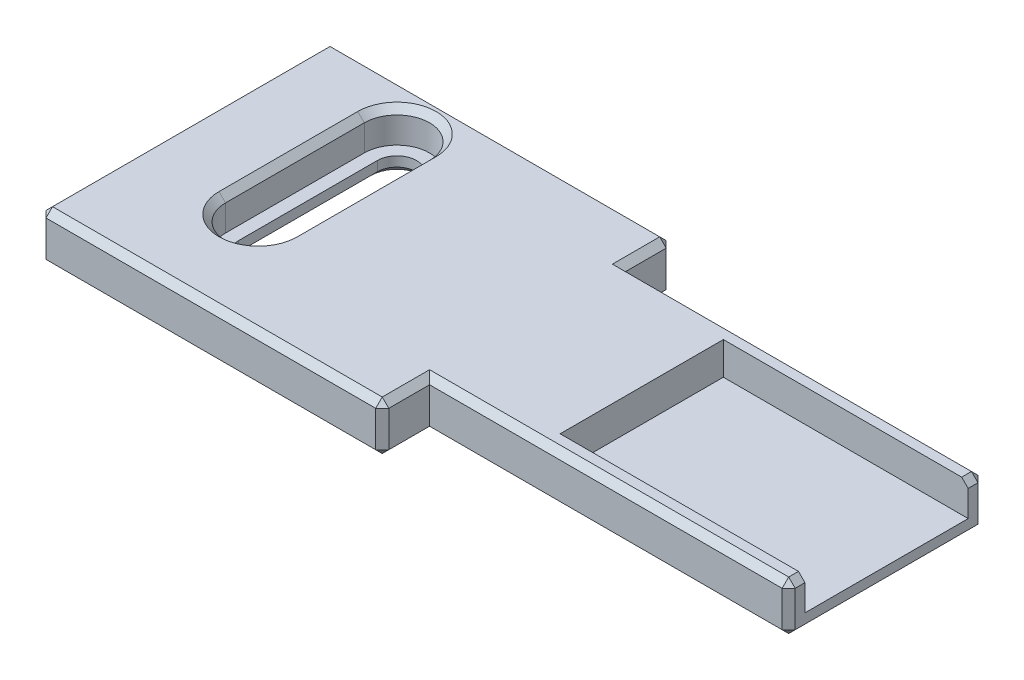
from build123d import *

# Parameters (mm, degrees)
SKETCH1_W           = 43
SKETCH1_H           = 17.8
BOSS_EXTRUDE1_DEPTH = 3
SKETCH2_W           = 22
SKETCH2_H           = 2.9
CUT_EXTRUDE1_DEPTH  = 4
SKETCH3_W           = 22
SKETCH3_H           = 2.9
CUT_EXTRUDE2_DEPTH  = 4
CUT_EXTRUDE3_DEPTH  = 2
CUT_EXTRUDE4_DEPTH  = 4
SKETCH6_W           = 10
SKETCH6_H           = 2
CUT_EXTRUDE5_DEPTH  = 15
CHAMFER1_SIZE       = 0.4


with BuildPart() as part:
    # Sketch1 → Boss-Extrude1 (new body)
    with BuildSketch(Plane(origin=(0, 38, 0), x_dir=(1, 0, 0), z_dir=(0, 1, 0))):
        with Locations((-6.5, 6)):
            Rectangle(SKETCH1_W, SKETCH1_H)
    extrude(amount=-BOSS_EXTRUDE1_DEPTH)

    # Sketch2 → Cut-Extrude1 (cut, through all)
    with BuildSketch(Plane.XZ.offset(-35)):
        with Locations((4, 1.45)):
            Rectangle(SKETCH2_W, SKETCH2_H)
    extrude(amount=-CUT_EXTRUDE1_DEPTH, mode=Mode.SUBTRACT)

    # Sketch3 → Cut-Extrude2 (cut, through all)
    with BuildSketch(Plane.XZ.offset(-35)):
        with Locations((4, -13.45)):
            Rectangle(SKETCH3_W, SKETCH3_H)
    extrude(amount=-CUT_EXTRUDE2_DEPTH, mode=Mode.SUBTRACT)

    # Sketch4 → Cut-Extrude3 (cut)
    with BuildSketch(Plane(origin=(0, 38, 0), x_dir=(-1, 0, 0), z_dir=(0, 1, 0))):
        with BuildLine():
            Line((22.9, -11.9), (22.9, -3.4))
            ThreePointArc((22.9, -3.4), (20.9, -1.4), (18.9, -3.4))
            Line((18.9, -3.4), (18.9, -11.9))
            ThreePointArc((18.9, -11.9), (20.9, -13.9), (22.9, -11.9))
        make_face()
    extrude(amount=-CUT_EXTRUDE3_DEPTH, mode=Mode.SUBTRACT)

    # Sketch5 → Cut-Extrude4 (cut, through all)
    with BuildSketch(Plane.XZ.offset(-35)):
        with BuildLine():
            Line((-22.1, -3.4), (-22.1, -11.9))
            ThreePointArc((-22.1, -11.9), (-20.9, -13.1), (-19.7, -11.9))
            Line((-19.7, -11.9), (-19.7, -3.4))
            ThreePointArc((-19.7, -3.4), (-20.9, -2.2), (-22.1, -3.4))
        make_face()
    extrude(amount=-CUT_EXTRUDE4_DEPTH, mode=Mode.SUBTRACT)

    # Sketch6 → Cut-Extrude5 (cut)
    with BuildSketch(Plane(origin=(15, 0, 0), x_dir=(0, 0, -1), z_dir=(1, 0, 0))):
        with Locations((6, 37)):
            Rectangle(SKETCH6_W, SKETCH6_H)
    extrude(amount=-CUT_EXTRUDE5_DEPTH, mode=Mode.SUBTRACT)

    # Chamfer1
    chamfer1_edges = [part.edges().sort_by_distance(p)[0] for p in [
        (15, 38, -0.5),
        (15, 35, -6),
        (-7, 36.5, 2.9),
        (4, 38, 0),
        (15, 36.5, 0),
        (-7, 38, 1.45),
        (-7, 35, 1.45),
        (4, 35, 0),
        (-17.5, 38, -14.9),
        (-17.5, 35, -14.9),
        (15, 36.5, -12),
        (-7, 38, -13.45),
        (-7, 36.5, -14.9),
        (4, 38, -12),
        (4, 35, -12),
        (-7, 35, -13.45),
        (-20.9, 38, -13.9),
        (-22.9, 38, -7.65),
        (-20.9, 38, -1.4),
        (-28, 35, -6),
        (-18.9, 38, -7.65),
        (-17.5, 38, 2.9),
        (-28, 38, -6),
        (-20.9, 35, -2.2),
        (-22.1, 35, -7.65),
        (-20.9, 35, -13.1),
        (-19.7, 35, -7.65),
        (-28, 36.5, -14.9),
        (15, 38, -11.5),
        (-28, 36.5, 2.9),
        (-17.5, 35, 2.9),
    ]]
    chamfer(chamfer1_edges, length=CHAMFER1_SIZE)


solid = part.part
